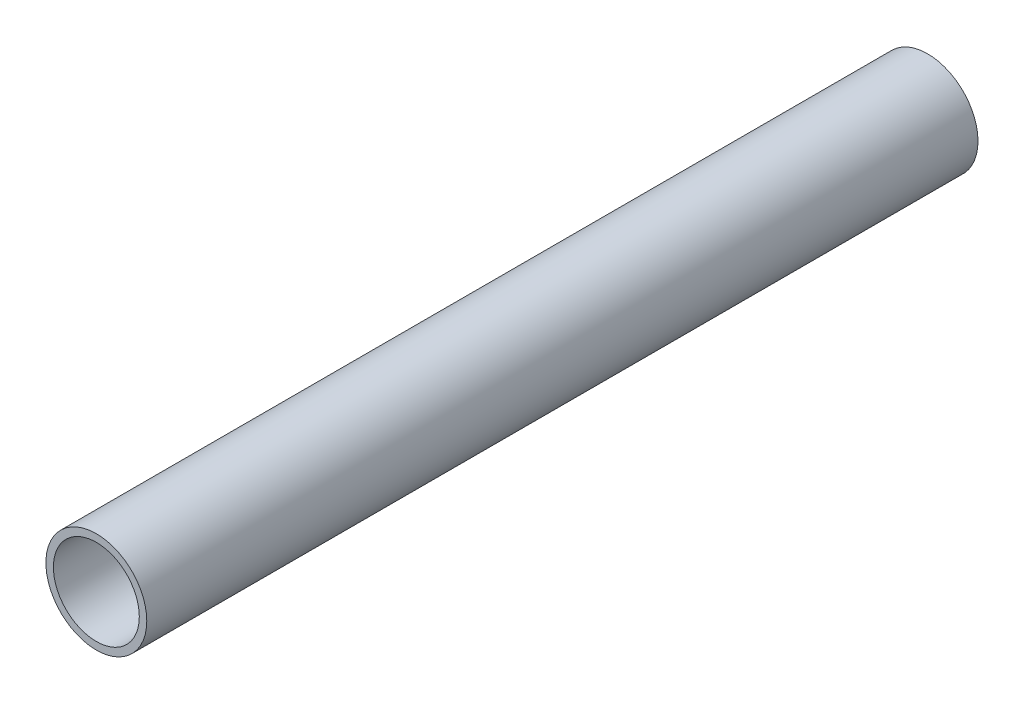
from build123d import *

# Parameters (mm, degrees)
SKETCH1_R           = 2.7
SKETCH1_R_2         = 2.3
BOSS_EXTRUDE1_DEPTH = 44.5


with BuildPart() as part:
    # Sketch1 → Boss-Extrude1 (new body)
    with BuildSketch(Plane.XY):
        Circle(SKETCH1_R)
        Circle(SKETCH1_R_2, mode=Mode.SUBTRACT)
    extrude(amount=BOSS_EXTRUDE1_DEPTH)


solid = part.part
